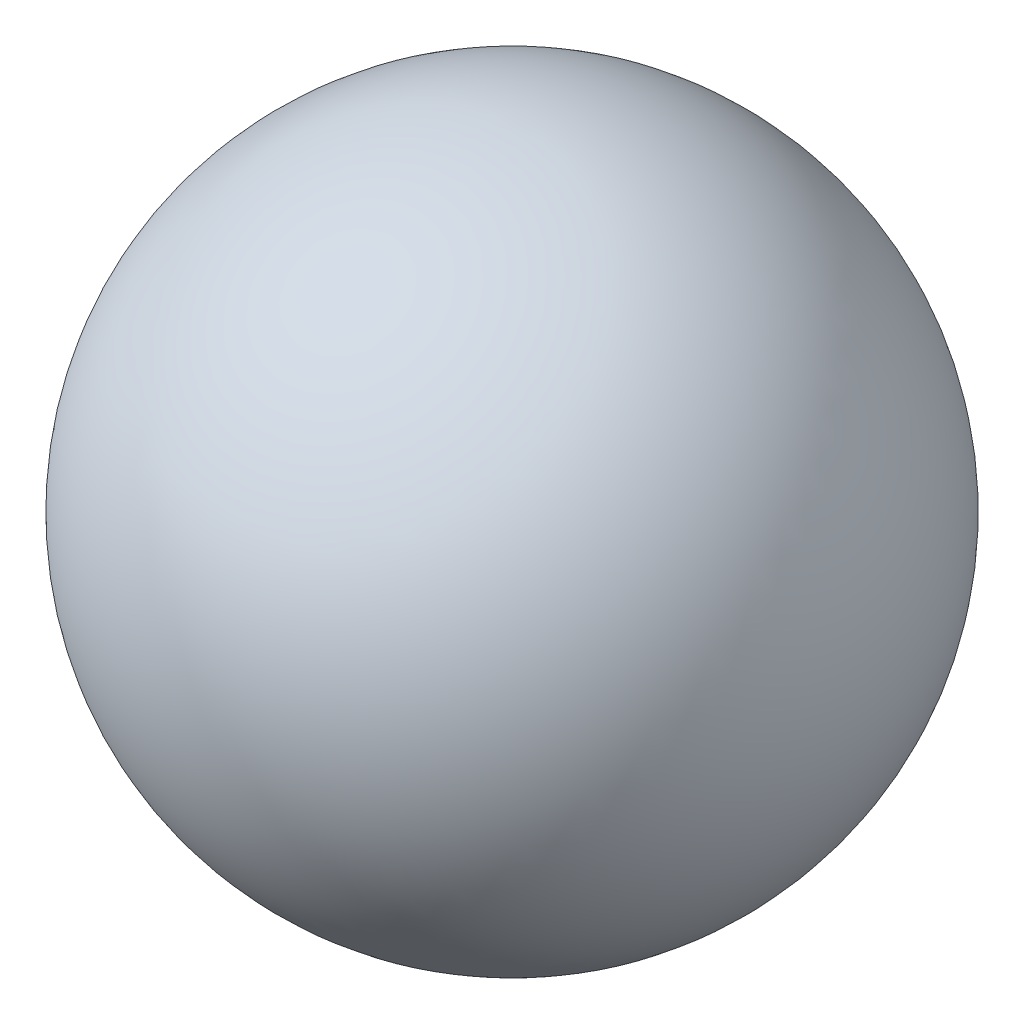
from build123d import *


with BuildPart() as part:
    # Esquisse1 → Révolution1 (revolve)
    with BuildSketch(Plane.XY):
        with BuildLine():
            Line((0, 30), (0, -30))
            ThreePointArc((0, -30), (30, 0), (0, 30))
        make_face()
    revolve(axis=Axis((0, 60.174418605, 0), (0, -1, 0)))


solid = part.part
